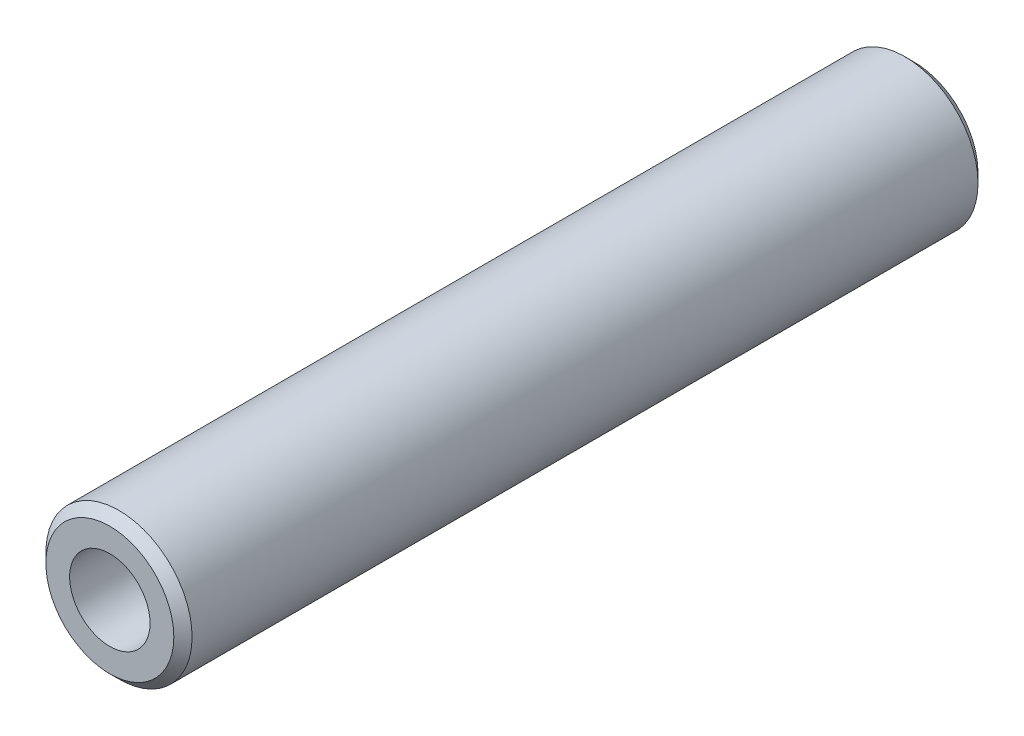
from build123d import *

# Parameters (mm, degrees)
ESQUISSE1_R        = 4
ESQUISSE1_R_2      = 2.2
BOSS_EXTRU_1_DEPTH = 22
CHAMFER1_SIZE      = 0.5


with BuildPart() as part:
    # Esquisse1 → Boss.-Extru.1 (new body, symmetric)
    with BuildSketch(Plane.XY):
        Circle(ESQUISSE1_R)
        Circle(ESQUISSE1_R_2, mode=Mode.SUBTRACT)
    extrude(amount=BOSS_EXTRU_1_DEPTH, both=True)

    # Chamfer1
    chamfer1_edges = [part.edges().sort_by_distance(p)[0] for p in [
        (-4, 0, -22),
        (-4, 0, 22),
    ]]
    chamfer(chamfer1_edges, length=CHAMFER1_SIZE)


solid = part.part
